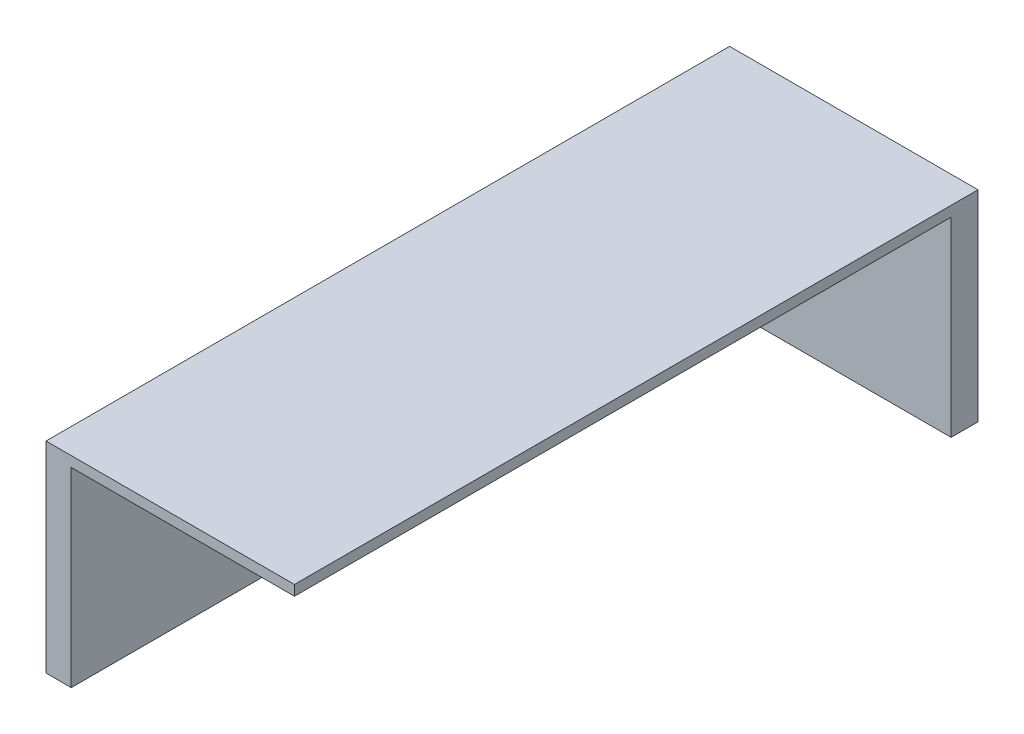
from build123d import *

# Parameters (mm, degrees)
SKETCH1_R           = 28.1
BOSS_EXTRUDE1_DEPTH = 1
SKETCH2_R           = 18.6
CUT_EXTRUDE1_DEPTH  = 58.8
SKETCH3_W           = 222.683092022
SKETCH3_H           = 364.2827524
BOSS_EXTRUDE2_DEPTH = 58.8
SKETCH4_W           = 207.917403516
SKETCH4_H           = 348.54429772
CUT_EXTRUDE2_DEPTH  = 55.8
SKETCH9_R           = 3
CUT_EXTRUDE8_DEPTH  = 10
SKETCH10_R          = 3.75
CUT_EXTRUDE9_DEPTH  = 10
CUT_EXTRUDE12_DEPTH = 500
SKETCH6_R           = 3.75
CUT_EXTRUDE5_DEPTH  = 400
SKETCH8_R           = 10
CUT_EXTRUDE7_DEPTH  = 10


with BuildPart() as part:
    # Sketch1 → Boss-Extrude1 (new body)
    with BuildSketch(Plane(origin=(0, 0, 0), x_dir=(1, 0, 0), z_dir=(0, 1, 0))):
        Circle(SKETCH1_R)
    extrude(amount=BOSS_EXTRUDE1_DEPTH)

    # Sketch2 → Cut-Extrude1 (cut)
    with BuildSketch(Plane(origin=(0, 1, 0), x_dir=(1, 0, 0), z_dir=(0, 1, 0))):
        with Locations((0, -7)):
            Circle(SKETCH2_R)
    extrude(amount=-CUT_EXTRUDE1_DEPTH, mode=Mode.SUBTRACT)

    # Sketch3 → Boss-Extrude2 (add)
    with BuildSketch(Plane(origin=(0, 0, 0), x_dir=(-1, 0, 0), z_dir=(0, -1, 0))):
        Rectangle(SKETCH3_W, SKETCH3_H)
    extrude(amount=BOSS_EXTRUDE2_DEPTH)

    # Sketch4 → Cut-Extrude2 (cut)
    with BuildSketch(Plane(origin=(0, -58.8, 0), x_dir=(-1, 0, 0), z_dir=(0, -1, 0))):
        Rectangle(SKETCH4_W, SKETCH4_H)
    extrude(amount=-CUT_EXTRUDE2_DEPTH, mode=Mode.SUBTRACT)

    # Sketch9 → Cut-Extrude8 (cut)
    with BuildSketch(Plane(origin=(0, 0, 0), x_dir=(1, 0, 0), z_dir=(0, 1, 0))):
        with Locations((0, -7)):
            Circle(SKETCH9_R)
    extrude(amount=-CUT_EXTRUDE8_DEPTH, mode=Mode.SUBTRACT)

    # Sketch10 → Cut-Extrude9 (cut)
    with BuildSketch(Plane(origin=(0, 1, 0), x_dir=(1, 0, 0), z_dir=(0, 1, 0))):
        with Locations((0, 19.85)):
            Circle(SKETCH10_R)
    extrude(amount=-CUT_EXTRUDE9_DEPTH, mode=Mode.SUBTRACT)

    # Sketch11 → Cut-Extrude12 (cut)
    with BuildSketch(Plane(origin=(0, -58.8, 0), x_dir=(-1, 0, 0), z_dir=(0, -1, 0))):
        Polygon((38.658453989, -17.8586238), (111.341546011, -17.8586238), (111.341546011, -182.1413762), (-111.341546011, -182.1413762), (-111.341546011, 182.1413762), (38.658453989, 182.1413762), align=None)
    extrude(amount=-CUT_EXTRUDE12_DEPTH, mode=Mode.SUBTRACT)

    # Sketch6 → Cut-Extrude5 (cut)
    with BuildSketch(Plane(origin=(0, 1, 0), x_dir=(1, 0, 0), z_dir=(0, 1, 0))):
        with Locations((0, 18.75)):
            Circle(SKETCH6_R)
    extrude(amount=-CUT_EXTRUDE5_DEPTH, mode=Mode.SUBTRACT)

    # Sketch8 → Cut-Extrude7 (cut)
    with BuildSketch(Plane(origin=(0, 0, -182.1413762), x_dir=(-1, 0, 0), z_dir=(0, 0, -1))):
        with Locations((-86.573671766, -25.011155335)):
            Circle(SKETCH8_R)
    extrude(amount=-CUT_EXTRUDE7_DEPTH, mode=Mode.SUBTRACT)


solid = part.part
